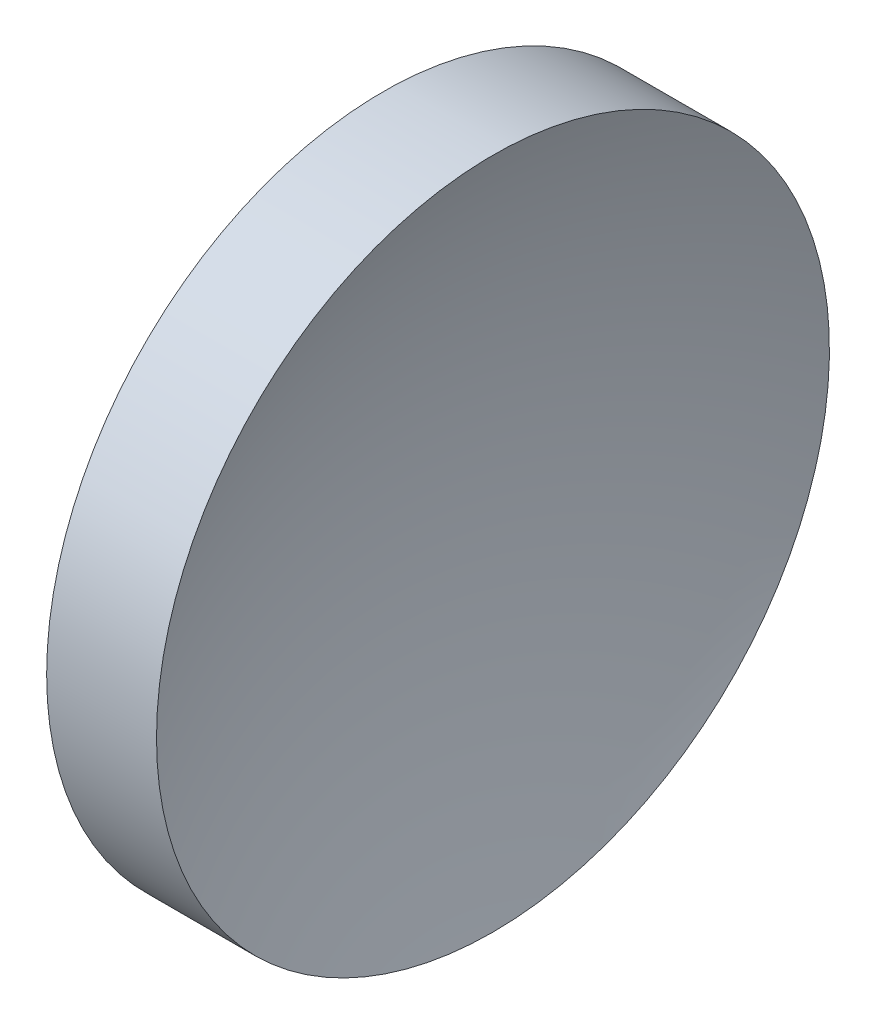
from build123d import *


with BuildPart() as part:
    # 草图1 → 旋转1 (revolve)
    with BuildSketch(Plane.XY, mode=Mode.PRIVATE) as revolve_1_sk:
        with BuildLine():
            Line((113.911931674, 65.155630457), (113.911931674, 85.155630457))
            Line((113.911931674, 85.155630457), (120.44216797, 85.155630457))
            ThreePointArc((120.44216797, 85.155630457), (117.42951669, 75.356645169), (116.411931674, 65.155630457))
            Line((116.411931674, 65.155630457), (113.911931674, 65.155630457))
        make_face()
    revolve(revolve_1_sk.sketch.rotate(Axis((105.621837124, 65.155630457, 0), (1, 0, 0)), 180), axis=Axis((105.621837124, 65.155630457, 0), (1, 0, 0)))  # turned: the seam where the file's is


solid = part.part
